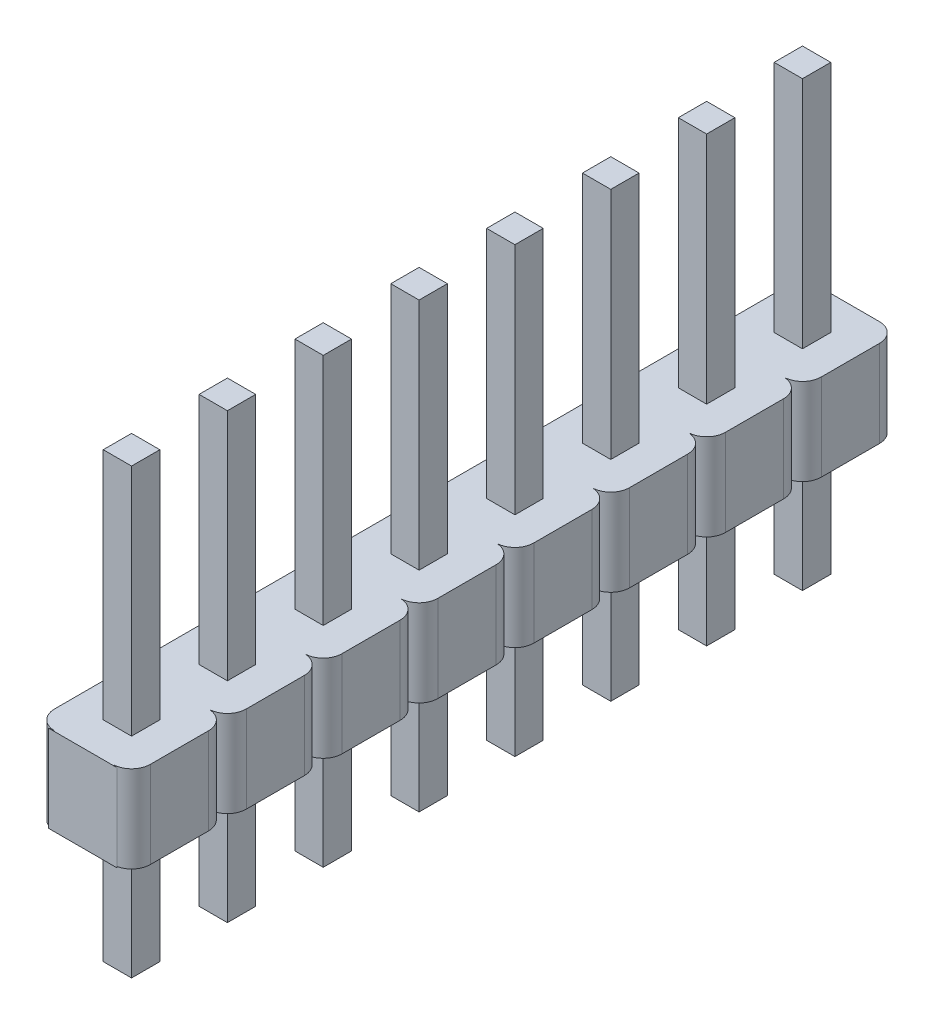
from build123d import *

# Parameters (mm, degrees)
CROQUIS1_W               = 2.54
CROQUIS1_H               = 20.34
SALIENTE_EXTRUIR1_DEPTH  = 2.3
CORTAR_EXTRUIR4_DEPTH    = 2.3
CORTAR_EXTRUIR5_DEPTH    = 2.3
CORTAR_EXTRUIR6_DEPTH    = 2.3
CORTAR_EXTRUIR7_DEPTH    = 2.3
CORTAR_EXTRUIR8_DEPTH    = 2.3
CORTAR_EXTRUIR9_DEPTH    = 2.3
CORTAR_EXTRUIR10_DEPTH   = 2.3
CORTAR_EXTRUIR11_DEPTH   = 2.3
CORTAR_EXTRUIR12_DEPTH   = 2.3
CORTAR_EXTRUIR13_DEPTH   = 2.3
CORTAR_EXTRUIR14_DEPTH   = 2.3
CORTAR_EXTRUIR15_DEPTH   = 2.3
CORTAR_EXTRUIR16_DEPTH   = 2.3
CORTAR_EXTRUIR17_DEPTH   = 2.3
CORTAR_EXTRUIR18_DEPTH   = 2.3
CORTAR_EXTRUIR19_DEPTH   = 2.3
CROQUIS24_W              = 0.75
CROQUIS24_H              = 0.75
SALIENTE_EXTRUIR2_DEPTH  = 3.25
CROQUIS25_W              = 0.75
CROQUIS25_H              = 0.75
SALIENTE_EXTRUIR3_DEPTH  = 6.2
CROQUIS26_W              = 0.75
CROQUIS26_H              = 0.75
SALIENTE_EXTRUIR4_DEPTH  = 6.2
CROQUIS27_W              = 0.75
CROQUIS27_H              = 0.75
SALIENTE_EXTRUIR5_DEPTH  = 6.2
CROQUIS28_W              = 0.75
CROQUIS28_H              = 0.75
SALIENTE_EXTRUIR6_DEPTH  = 6.2
CROQUIS29_W              = 0.75
CROQUIS29_H              = 0.75
SALIENTE_EXTRUIR7_DEPTH  = 6.2
CROQUIS30_W              = 0.75
CROQUIS30_H              = 0.75
SALIENTE_EXTRUIR8_DEPTH  = 6.2
CROQUIS31_W              = 0.75
CROQUIS31_H              = 0.75
SALIENTE_EXTRUIR9_DEPTH  = 6.2
CROQUIS32_W              = 0.75
CROQUIS32_H              = 0.75
SALIENTE_EXTRUIR10_DEPTH = 6.2
CROQUIS37_W              = 0.75
CROQUIS37_H              = 0.75
SALIENTE_EXTRUIR15_DEPTH = 3.25
CROQUIS38_W              = 0.75
CROQUIS38_H              = 0.75
SALIENTE_EXTRUIR16_DEPTH = 3.25
CROQUIS39_W              = 0.75
CROQUIS39_H              = 0.75
SALIENTE_EXTRUIR17_DEPTH = 3.25
CROQUIS40_W              = 0.75
CROQUIS40_H              = 0.75
SALIENTE_EXTRUIR18_DEPTH = 3.25
CROQUIS41_W              = 0.75
CROQUIS41_H              = 0.75
SALIENTE_EXTRUIR19_DEPTH = 3.25
CROQUIS42_W              = 0.75
CROQUIS42_H              = 0.75
SALIENTE_EXTRUIR20_DEPTH = 3.25
CROQUIS43_W              = 0.75
CROQUIS43_H              = 0.75
SALIENTE_EXTRUIR21_DEPTH = 3.25
REDONDEO2_R              = 0.5


with BuildPart() as part:
    # Croquis1 → Saliente-Extruir1 (new body)
    with BuildSketch(Plane(origin=(0, 2.3, 0), x_dir=(1, 0, 0), z_dir=(0, 1, 0))):
        with Locations((0, -8.9)):
            Rectangle(CROQUIS1_W, CROQUIS1_H)
    extrude(amount=-SALIENTE_EXTRUIR1_DEPTH)

    # Croquis5 → Cortar-Extruir4 (cut)
    with BuildSketch(Plane.XZ):
        with BuildLine():
            Line((1.27, 18.55), (1.27, 19.55))
            ThreePointArc((1.27, 19.55), (1.123553391, 19.196446609), (0.77, 19.05))
            ThreePointArc((0.77, 19.05), (1.123553391, 18.903553391), (1.27, 18.55))
        make_face()
    extrude(amount=-CORTAR_EXTRUIR4_DEPTH, mode=Mode.SUBTRACT)

    # Croquis6 → Cortar-Extruir5 (cut)
    with BuildSketch(Plane.XZ):
        with BuildLine():
            Line((1.27, 16.01), (1.27, 17.01))
            ThreePointArc((1.27, 17.01), (1.123553391, 16.656446609), (0.77, 16.51))
            ThreePointArc((0.77, 16.51), (1.123553391, 16.363553391), (1.27, 16.01))
        make_face()
    extrude(amount=-CORTAR_EXTRUIR5_DEPTH, mode=Mode.SUBTRACT)

    # Croquis7 → Cortar-Extruir6 (cut)
    with BuildSketch(Plane.XZ):
        with BuildLine():
            Line((1.27, 13.47), (1.27, 14.47))
            ThreePointArc((1.27, 14.47), (1.123553391, 14.116446609), (0.77, 13.97))
            ThreePointArc((0.77, 13.97), (1.123553391, 13.823553391), (1.27, 13.47))
        make_face()
    extrude(amount=-CORTAR_EXTRUIR6_DEPTH, mode=Mode.SUBTRACT)

    # Croquis8 → Cortar-Extruir7 (cut)
    with BuildSketch(Plane.XZ):
        with BuildLine():
            Line((1.27, 10.93), (1.27, 11.93))
            ThreePointArc((1.27, 11.93), (1.123553391, 11.576446609), (0.77, 11.43))
            ThreePointArc((0.77, 11.43), (1.123553391, 11.283553391), (1.27, 10.93))
        make_face()
    extrude(amount=-CORTAR_EXTRUIR7_DEPTH, mode=Mode.SUBTRACT)

    # Croquis9 → Cortar-Extruir8 (cut)
    with BuildSketch(Plane.XZ):
        with BuildLine():
            Line((1.27, 8.39), (1.27, 9.39))
            ThreePointArc((1.27, 9.39), (1.123553391, 9.036446609), (0.77, 8.89))
            ThreePointArc((0.77, 8.89), (1.123553391, 8.743553391), (1.27, 8.39))
        make_face()
    extrude(amount=-CORTAR_EXTRUIR8_DEPTH, mode=Mode.SUBTRACT)

    # Croquis10 → Cortar-Extruir9 (cut)
    with BuildSketch(Plane.XZ):
        with BuildLine():
            Line((1.27, 5.85), (1.27, 6.85))
            ThreePointArc((1.27, 6.85), (1.123553391, 6.496446609), (0.77, 6.35))
            ThreePointArc((0.77, 6.35), (1.123553391, 6.203553391), (1.27, 5.85))
        make_face()
    extrude(amount=-CORTAR_EXTRUIR9_DEPTH, mode=Mode.SUBTRACT)

    # Croquis11 → Cortar-Extruir10 (cut)
    with BuildSketch(Plane.XZ):
        with BuildLine():
            Line((1.27, 3.31), (1.27, 4.31))
            ThreePointArc((1.27, 4.31), (1.123553391, 3.956446609), (0.77, 3.81))
            ThreePointArc((0.77, 3.81), (1.123553391, 3.663553391), (1.27, 3.31))
        make_face()
    extrude(amount=-CORTAR_EXTRUIR10_DEPTH, mode=Mode.SUBTRACT)

    # Croquis12 → Cortar-Extruir11 (cut)
    with BuildSketch(Plane.XZ):
        with BuildLine():
            Line((1.27, 0.77), (1.27, 1.77))
            ThreePointArc((1.27, 1.77), (1.123553391, 1.416446609), (0.77, 1.27))
            ThreePointArc((0.77, 1.27), (1.123553391, 1.123553391), (1.27, 0.77))
        make_face()
    extrude(amount=-CORTAR_EXTRUIR11_DEPTH, mode=Mode.SUBTRACT)

    # Croquis13 → Cortar-Extruir12 (cut)
    with BuildSketch(Plane.XZ):
        with BuildLine():
            Line((-1.27, 1.77), (-1.27, 0.77))
            ThreePointArc((-1.27, 0.77), (-1.123553391, 1.123553391), (-0.77, 1.27))
            ThreePointArc((-0.77, 1.27), (-1.123553391, 1.416446609), (-1.27, 1.77))
        make_face()
    extrude(amount=-CORTAR_EXTRUIR12_DEPTH, mode=Mode.SUBTRACT)

    # Croquis14 → Cortar-Extruir13 (cut)
    with BuildSketch(Plane.XZ):
        with BuildLine():
            Line((-1.27, 4.31), (-1.27, 3.31))
            ThreePointArc((-1.27, 3.31), (-1.123553391, 3.663553391), (-0.77, 3.81))
            ThreePointArc((-0.77, 3.81), (-1.123553391, 3.956446609), (-1.27, 4.31))
        make_face()
    extrude(amount=-CORTAR_EXTRUIR13_DEPTH, mode=Mode.SUBTRACT)

    # Croquis15 → Cortar-Extruir14 (cut)
    with BuildSketch(Plane.XZ):
        with BuildLine():
            Line((-1.27, 6.85), (-1.27, 5.85))
            ThreePointArc((-1.27, 5.85), (-1.123553391, 6.203553391), (-0.77, 6.35))
            ThreePointArc((-0.77, 6.35), (-1.123553391, 6.496446609), (-1.27, 6.85))
        make_face()
    extrude(amount=-CORTAR_EXTRUIR14_DEPTH, mode=Mode.SUBTRACT)

    # Croquis16 → Cortar-Extruir15 (cut)
    with BuildSketch(Plane.XZ):
        with BuildLine():
            Line((-1.27, 9.39), (-1.27, 8.39))
            ThreePointArc((-1.27, 8.39), (-1.123553391, 8.743553391), (-0.77, 8.89))
            ThreePointArc((-0.77, 8.89), (-1.123553391, 9.036446609), (-1.27, 9.39))
        make_face()
    extrude(amount=-CORTAR_EXTRUIR15_DEPTH, mode=Mode.SUBTRACT)

    # Croquis17 → Cortar-Extruir16 (cut)
    with BuildSketch(Plane.XZ):
        with BuildLine():
            Line((-1.27, 11.93), (-1.27, 10.93))
            ThreePointArc((-1.27, 10.93), (-1.123553391, 11.283553391), (-0.77, 11.43))
            ThreePointArc((-0.77, 11.43), (-1.123553391, 11.576446609), (-1.27, 11.93))
        make_face()
    extrude(amount=-CORTAR_EXTRUIR16_DEPTH, mode=Mode.SUBTRACT)

    # Croquis18 → Cortar-Extruir17 (cut)
    with BuildSketch(Plane.XZ):
        with BuildLine():
            Line((-1.27, 14.47), (-1.27, 13.47))
            ThreePointArc((-1.27, 13.47), (-1.123553391, 13.823553391), (-0.77, 13.97))
            ThreePointArc((-0.77, 13.97), (-1.123553391, 14.116446609), (-1.27, 14.47))
        make_face()
    extrude(amount=-CORTAR_EXTRUIR17_DEPTH, mode=Mode.SUBTRACT)

    # Croquis19 → Cortar-Extruir18 (cut)
    with BuildSketch(Plane.XZ):
        with BuildLine():
            Line((-1.27, 17.01), (-1.27, 16.01))
            ThreePointArc((-1.27, 16.01), (-1.123553391, 16.363553391), (-0.77, 16.51))
            ThreePointArc((-0.77, 16.51), (-1.123553391, 16.656446609), (-1.27, 17.01))
        make_face()
    extrude(amount=-CORTAR_EXTRUIR18_DEPTH, mode=Mode.SUBTRACT)

    # Croquis20 → Cortar-Extruir19 (cut)
    with BuildSketch(Plane.XZ):
        with BuildLine():
            Line((-1.27, 19.55), (-1.27, 18.55))
            ThreePointArc((-1.27, 18.55), (-1.123553391, 18.903553391), (-0.77, 19.05))
            ThreePointArc((-0.77, 19.05), (-1.123553391, 19.196446609), (-1.27, 19.55))
        make_face()
    extrude(amount=-CORTAR_EXTRUIR19_DEPTH, mode=Mode.SUBTRACT)

    # Croquis24 → Saliente-Extruir2 (add)
    with BuildSketch(Plane.XZ):
        Rectangle(CROQUIS24_W, CROQUIS24_H)
    extrude(amount=SALIENTE_EXTRUIR2_DEPTH)

    # Croquis25 → Saliente-Extruir3 (add)
    with BuildSketch(Plane(origin=(0, 2.3, 0), x_dir=(-1, 0, 0), z_dir=(0, 1, 0))):
        Rectangle(CROQUIS25_W, CROQUIS25_H)
    extrude(amount=SALIENTE_EXTRUIR3_DEPTH)

    # Croquis26 → Saliente-Extruir4 (add)
    with BuildSketch(Plane(origin=(0, 2.3, 0), x_dir=(-1, 0, 0), z_dir=(0, 1, 0))):
        with Locations((0, 2.54)):
            Rectangle(CROQUIS26_W, CROQUIS26_H)
    extrude(amount=SALIENTE_EXTRUIR4_DEPTH)

    # Croquis27 → Saliente-Extruir5 (add)
    with BuildSketch(Plane(origin=(0, 2.3, 0), x_dir=(-1, 0, 0), z_dir=(0, 1, 0))):
        with Locations((0, 5.08)):
            Rectangle(CROQUIS27_W, CROQUIS27_H)
    extrude(amount=SALIENTE_EXTRUIR5_DEPTH)

    # Croquis28 → Saliente-Extruir6 (add)
    with BuildSketch(Plane(origin=(0, 2.3, 0), x_dir=(-1, 0, 0), z_dir=(0, 1, 0))):
        with Locations((0, 7.62)):
            Rectangle(CROQUIS28_W, CROQUIS28_H)
    extrude(amount=SALIENTE_EXTRUIR6_DEPTH)

    # Croquis29 → Saliente-Extruir7 (add)
    with BuildSketch(Plane(origin=(0, 2.3, 0), x_dir=(-1, 0, 0), z_dir=(0, 1, 0))):
        with Locations((0, 10.16)):
            Rectangle(CROQUIS29_W, CROQUIS29_H)
    extrude(amount=SALIENTE_EXTRUIR7_DEPTH)

    # Croquis30 → Saliente-Extruir8 (add)
    with BuildSketch(Plane(origin=(0, 2.3, 0), x_dir=(-1, 0, 0), z_dir=(0, 1, 0))):
        with Locations((0, 12.7)):
            Rectangle(CROQUIS30_W, CROQUIS30_H)
    extrude(amount=SALIENTE_EXTRUIR8_DEPTH)

    # Croquis31 → Saliente-Extruir9 (add)
    with BuildSketch(Plane(origin=(0, 2.3, 0), x_dir=(-1, 0, 0), z_dir=(0, 1, 0))):
        with Locations((0, 15.24)):
            Rectangle(CROQUIS31_W, CROQUIS31_H)
    extrude(amount=SALIENTE_EXTRUIR9_DEPTH)

    # Croquis32 → Saliente-Extruir10 (add)
    with BuildSketch(Plane(origin=(0, 2.3, 0), x_dir=(-1, 0, 0), z_dir=(0, 1, 0))):
        with Locations((0, 17.78)):
            Rectangle(CROQUIS32_W, CROQUIS32_H)
    extrude(amount=SALIENTE_EXTRUIR10_DEPTH)

    # Croquis37 → Saliente-Extruir15 (add)
    with BuildSketch(Plane.XZ):
        with Locations((0, 2.54)):
            Rectangle(CROQUIS37_W, CROQUIS37_H)
    extrude(amount=SALIENTE_EXTRUIR15_DEPTH)

    # Croquis38 → Saliente-Extruir16 (add)
    with BuildSketch(Plane.XZ):
        with Locations((0, 5.08)):
            Rectangle(CROQUIS38_W, CROQUIS38_H)
    extrude(amount=SALIENTE_EXTRUIR16_DEPTH)

    # Croquis39 → Saliente-Extruir17 (add)
    with BuildSketch(Plane.XZ):
        with Locations((0, 7.62)):
            Rectangle(CROQUIS39_W, CROQUIS39_H)
    extrude(amount=SALIENTE_EXTRUIR17_DEPTH)

    # Croquis40 → Saliente-Extruir18 (add)
    with BuildSketch(Plane.XZ):
        with Locations((0, 10.16)):
            Rectangle(CROQUIS40_W, CROQUIS40_H)
    extrude(amount=SALIENTE_EXTRUIR18_DEPTH)

    # Croquis41 → Saliente-Extruir19 (add)
    with BuildSketch(Plane.XZ):
        with Locations((0, 12.7)):
            Rectangle(CROQUIS41_W, CROQUIS41_H)
    extrude(amount=SALIENTE_EXTRUIR19_DEPTH)

    # Croquis42 → Saliente-Extruir20 (add)
    with BuildSketch(Plane.XZ):
        with Locations((0, 15.24)):
            Rectangle(CROQUIS42_W, CROQUIS42_H)
    extrude(amount=SALIENTE_EXTRUIR20_DEPTH)

    # Croquis43 → Saliente-Extruir21 (add)
    with BuildSketch(Plane.XZ):
        with Locations((0, 17.78)):
            Rectangle(CROQUIS43_W, CROQUIS43_H)
    extrude(amount=SALIENTE_EXTRUIR21_DEPTH)

    # Redondeo2
    redondeo2_edges = [part.edges().sort_by_distance(p)[0] for p in [
        (-1.27, 1.15, -1.27),
        (1.27, 1.15, -1.27),
    ]]
    fillet(redondeo2_edges, radius=REDONDEO2_R)


solid = part.part
